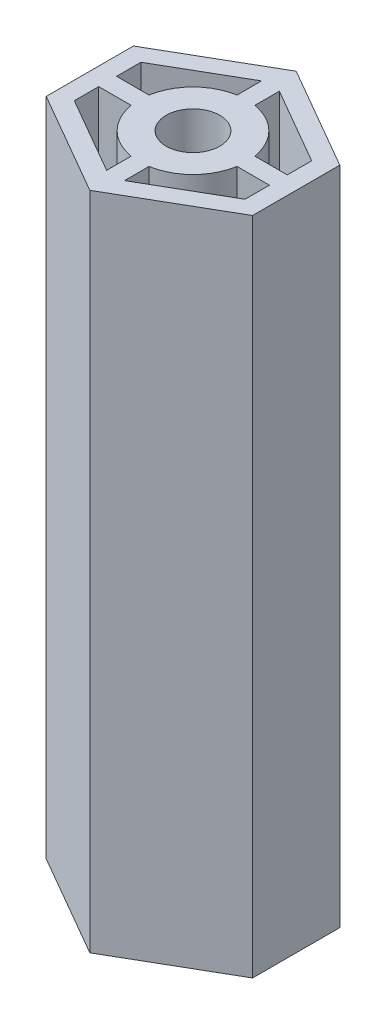
from build123d import *

# Parameters (mm, degrees)
SKETCH1_R           = 3.25
BOSS_EXTRUDE2_DEPTH = 80


with BuildPart() as part:
    # Sketch1 → Boss-Extrude2 (new body)
    with BuildSketch(Plane(origin=(0, 0, 0), x_dir=(1, 0, 0), z_dir=(0, 1, 0))):
        Polygon((-12.5, 5.283121635), (-12.5, -5.283121635), (0, -12.5), (12.5, -5.283121635), (12.5, 5.283121635), (0, 12.5), align=None)
        Circle(SKETCH1_R, mode=Mode.SUBTRACT)
        with BuildLine():
            Line((-1.08, 9.382308546), (-1.08, 6.409648976))
            ThreePointArc((-1.08, 6.409648976), (-4.596194078, 4.596194078), (-6.409648976, 1.08))
            Line((-6.409648976, 1.08), (-10.34, 1.08))
            Line((-10.34, 1.08), (-10.34, 4.036045054))
            Line((-10.34, 4.036045054), (-1.08, 9.382308546))
        make_face(mode=Mode.SUBTRACT)
        with BuildLine():
            Line((1.08, 9.382308546), (1.08, 6.409648976))
            ThreePointArc((1.08, 6.409648976), (4.596194078, 4.596194078), (6.409648976, 1.08))
            Line((6.409648976, 1.08), (10.34, 1.08))
            Line((10.34, 1.08), (10.34, 4.036045054))
            Line((10.34, 4.036045054), (1.08, 9.382308546))
        make_face(mode=Mode.SUBTRACT)
        with BuildLine():
            Line((-10.34, -1.08), (-6.409648976, -1.08))
            ThreePointArc((-6.409648976, -1.08), (-4.596194078, -4.596194078), (-1.08, -6.409648976))
            Line((-1.08, -6.409648976), (-1.08, -9.382308546))
            Line((-1.08, -9.382308546), (-10.34, -4.036045054))
            Line((-10.34, -4.036045054), (-10.34, -1.08))
        make_face(mode=Mode.SUBTRACT)
        with BuildLine():
            Line((1.08, -6.409648976), (1.08, -9.382308546))
            Line((1.08, -9.382308546), (10.34, -4.036045054))
            Line((10.34, -4.036045054), (10.34, -1.08))
            Line((10.34, -1.08), (6.409648976, -1.08))
            ThreePointArc((6.409648976, -1.08), (4.596194078, -4.596194078), (1.08, -6.409648976))
        make_face(mode=Mode.SUBTRACT)
    extrude(amount=BOSS_EXTRUDE2_DEPTH)


solid = part.part
